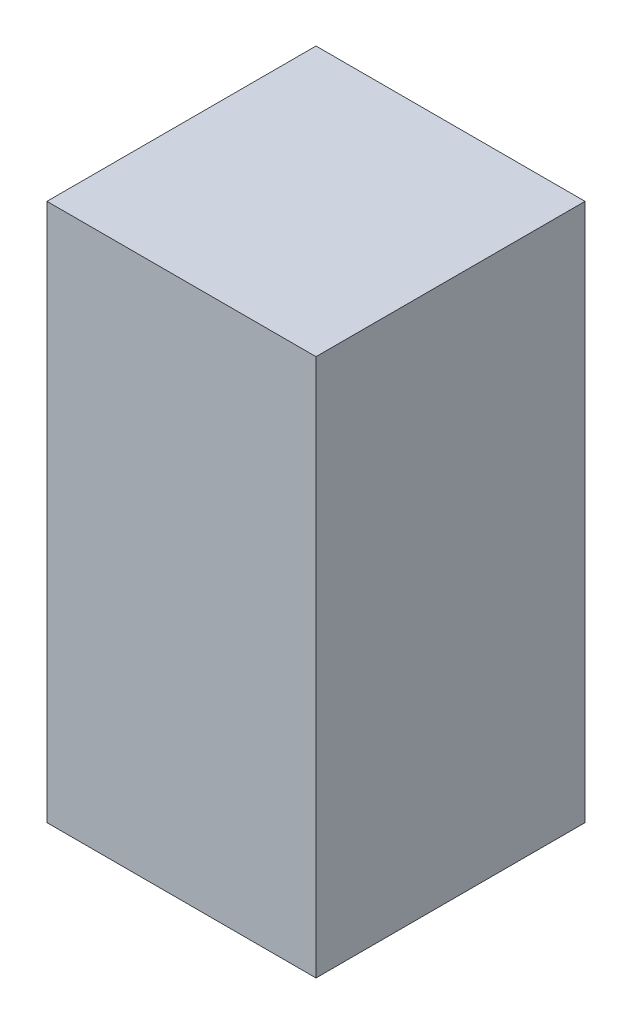
from build123d import *

# Parameters (mm, degrees)
SKETCH1_W           = 200
SKETCH1_H           = 200
BOSS_EXTRUDE1_DEPTH = 400


with BuildPart() as part:
    # Sketch1 → Boss-Extrude1 (new body)
    with BuildSketch(Plane(origin=(0, 0, 0), x_dir=(1, 0, 0), z_dir=(0, 1, 0))):
        with Locations((100, -100)):
            Rectangle(SKETCH1_W, SKETCH1_H)
    extrude(amount=BOSS_EXTRUDE1_DEPTH)


solid = part.part
